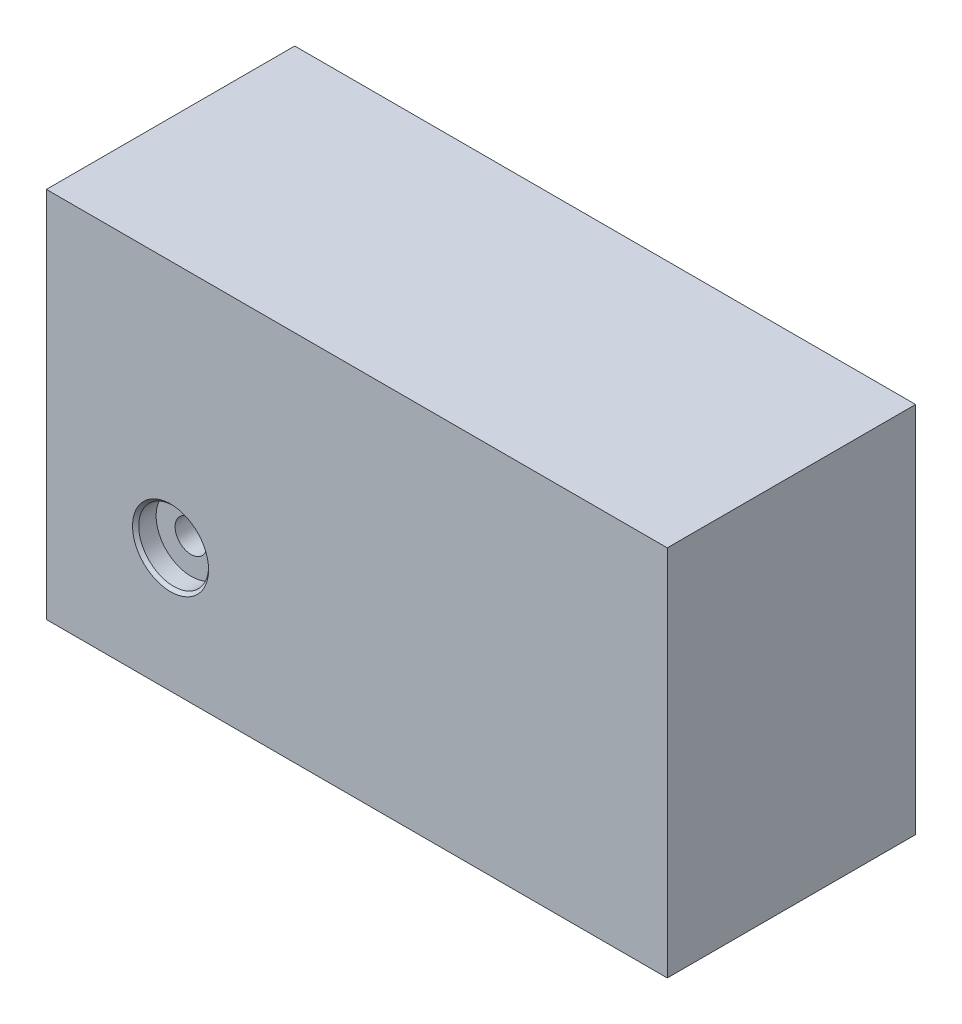
from build123d import *

# Parameters (mm, degrees)
SKETCH2_W           = 127
SKETCH2_H           = 76.2
BOSS_EXTRUDE1_DEPTH = 50.8


with BuildPart() as part:
    # Sketch2 → Boss-Extrude1 (new body)
    with BuildSketch(Plane.XY):
        with Locations((63.5, 38.1)):
            Rectangle(SKETCH2_W, SKETCH2_H)
    extrude(amount=BOSS_EXTRUDE1_DEPTH)

    # Sketch5 → CBORE for 1/4 Binding Head Machine Screw1 (revolve, cut)
    with BuildSketch(Plane(origin=(25.4, 25.4, 50.8), x_dir=(0, -1, 0), z_dir=(1, 0, 0))):
        Polygon((0, 0), (0, 50.8), (3.2639, 50.8), (3.2639, 4.191), (7.14375, 4.191), (7.14375, 0.635), (7.77875, 0), align=None)
    revolve(axis=Axis((25.4, 25.4, 57.15), (0, 0, -1)), mode=Mode.SUBTRACT)


solid = part.part
